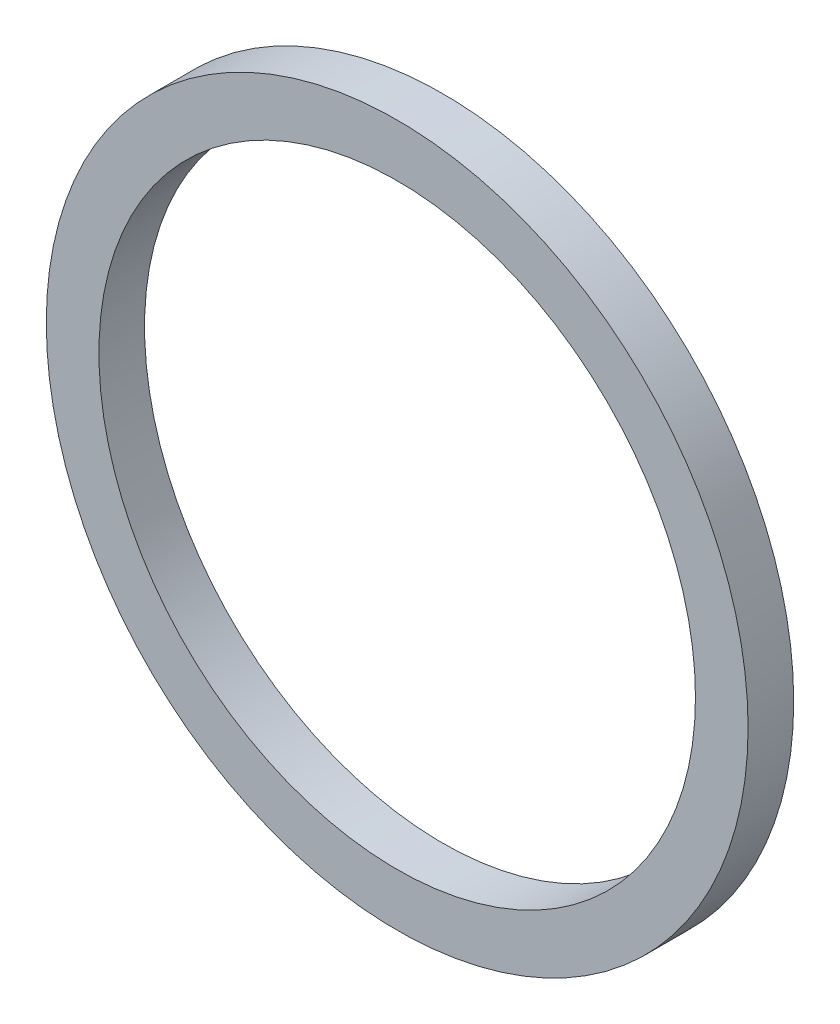
from build123d import *

# Parameters (mm, degrees)
SKETCH1_R           = 10
SKETCH1_R_2         = 8.5
BOSS_EXTRUDE1_DEPTH = 1.3


with BuildPart() as part:
    # Sketch1 → Boss-Extrude1 (new body)
    with BuildSketch(Plane.XY):
        Circle(SKETCH1_R)
        Circle(SKETCH1_R_2, mode=Mode.SUBTRACT)
    extrude(amount=BOSS_EXTRUDE1_DEPTH)


solid = part.part
